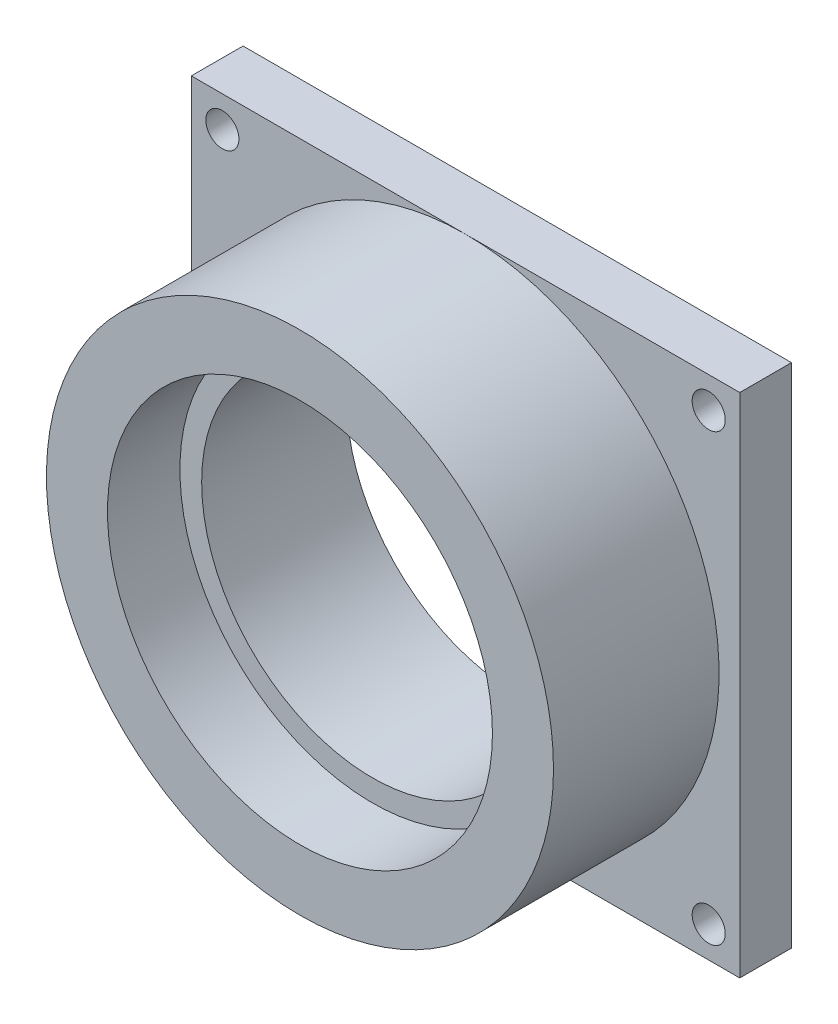
from build123d import *

# Parameters (mm, degrees)
SKETCH1_W           = 53
SKETCH1_H           = 49
BOSS_EXTRUDE1_DEPTH = 5
SKETCH2_R           = 24.5
BOSS_EXTRUDE2_DEPTH = 16
SKETCH4_R           = 1.6
CUT_EXTRUDE1_DEPTH  = 22
SKETCH5_R           = 18.6
CUT_EXTRUDE2_DEPTH  = 7
SKETCH6_R           = 16.5
CUT_EXTRUDE3_DEPTH  = 15


with BuildPart() as part:
    # Sketch1 → Boss-Extrude1 (new body)
    with BuildSketch(Plane.XY):
        Rectangle(SKETCH1_W, SKETCH1_H)
    extrude(amount=BOSS_EXTRUDE1_DEPTH)

    # Sketch2 → Boss-Extrude2 (add)
    with BuildSketch(Plane.XY.offset(5)):
        Circle(SKETCH2_R)
    extrude(amount=BOSS_EXTRUDE2_DEPTH)

    # Sketch4 → Cut-Extrude1 (cut, through all)
    with BuildSketch(Plane(origin=(0, 0, 0), x_dir=(-1, 0, 0), z_dir=(0, 0, -1))):
        with Locations((23.5, -21.5)):
            Circle(SKETCH4_R)
        with Locations((-23.5, -21.5)):
            Circle(SKETCH4_R)
        with Locations((23.5, 21.5)):
            Circle(SKETCH4_R)
        with Locations((-23.5, 21.5)):
            Circle(SKETCH4_R)
    extrude(amount=-CUT_EXTRUDE1_DEPTH, mode=Mode.SUBTRACT)

    # Sketch5 → Cut-Extrude2 (cut)
    with BuildSketch(Plane.XY.offset(21)):
        Circle(SKETCH5_R)
    extrude(amount=-CUT_EXTRUDE2_DEPTH, mode=Mode.SUBTRACT)

    # Sketch6 → Cut-Extrude3 (cut, through all)
    with BuildSketch(Plane.XY.offset(14)):
        Circle(SKETCH6_R)
    extrude(amount=-CUT_EXTRUDE3_DEPTH, mode=Mode.SUBTRACT)


solid = part.part
